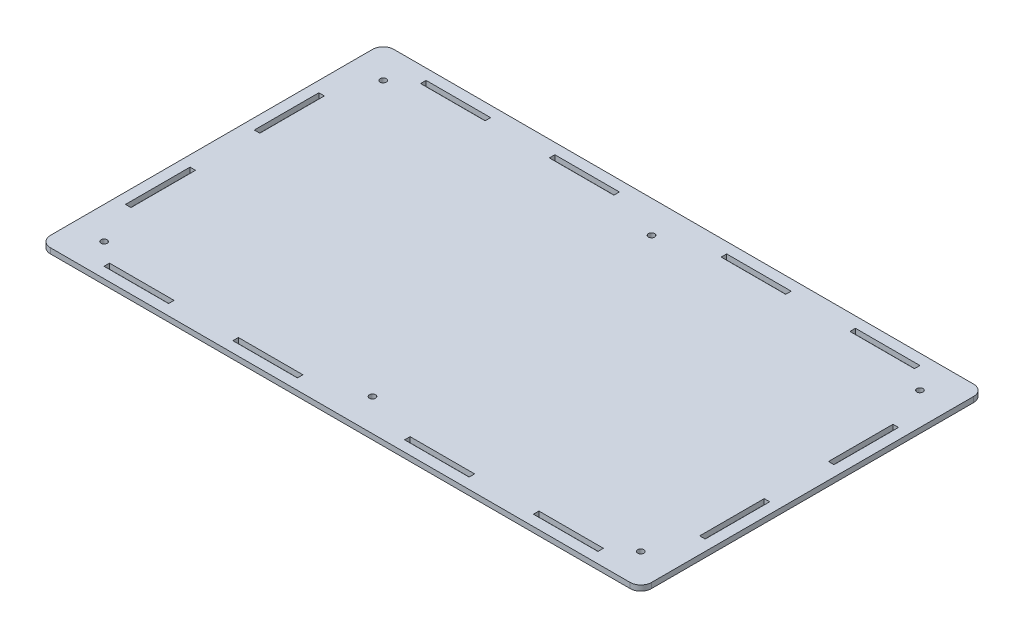
from build123d import *

# Parameters (mm, degrees)
PANEL_PROFILE_2_W       = 355.6
PANEL_PROFILE_2_H       = 203.2
PANEL_PROFILE_DEPTH     = 3.175
SKETCH8_R               = 1.8288
CUT_EXTRUDE1_DEPTH      = 10
FILLET1_R               = 6.35
SKETCH9_W               = 38.18
SKETCH9_H               = 3.25
CUT_EXTRUDE2_DEPTH      = 205.80595847
MIRROR2_COPY_1_SKETCH_W = 38.18
MIRROR2_COPY_1_SKETCH_H = 3.25
MIRROR2_COPY_1_DEPTH    = 205.80595847
SKETCH10_W              = 3.2512
SKETCH10_H              = 38.1762
CUT_EXTRUDE3_DEPTH      = 205.80595847
MIRROR4_COPY_1_SKETCH_W = 3.2512
MIRROR4_COPY_1_SKETCH_H = 38.1762
MIRROR4_COPY_1_DEPTH    = 205.80595847


with BuildPart() as part:
    # Panel Profile 2 → Panel-Profile (new body)
    with BuildSketch(Plane(origin=(0, 0, 0), x_dir=(1, 0, 0), z_dir=(0, 1, 0))):
        Rectangle(PANEL_PROFILE_2_W, PANEL_PROFILE_2_H)
    extrude(amount=-PANEL_PROFILE_DEPTH)

    # Sketch8 → Cut-Extrude1 (cut)
    with BuildSketch(Plane(origin=(0, 0, 0), x_dir=(1, 0, 0), z_dir=(0, 1, 0))):
        with Locations((-158.75, 82.55)):
            Circle(SKETCH8_R)
        with Locations((0, 82.55)):
            Circle(SKETCH8_R)
        with Locations((158.75, 82.55)):
            Circle(SKETCH8_R)
        with Locations((-158.75, -82.55)):
            Circle(SKETCH8_R)
        with Locations((0, -82.55)):
            Circle(SKETCH8_R)
        with Locations((158.75, -82.55)):
            Circle(SKETCH8_R)
    extrude(amount=-CUT_EXTRUDE1_DEPTH, mode=Mode.SUBTRACT)

    # Fillet1
    fillet1_edges = [part.edges().sort_by_distance(p)[0] for p in [
        (177.8, -1.5875, -101.6),
        (177.8, -1.5875, 101.6),
        (-177.8, -1.5875, 101.6),
        (-177.8, -1.5875, -101.6),
    ]]
    fillet(fillet1_edges, radius=FILLET1_R)

    # Sketch9 → Cut-Extrude2 (cut, symmetric)
    with BuildSketch(Plane(origin=(0, 0, 0), x_dir=(1, 0, 0), z_dir=(0, 1, 0))):
        with Locations((-127, 93.625)):
            Rectangle(SKETCH9_W, SKETCH9_H)
        with Locations((-50.8, 93.625)):
            Rectangle(SKETCH9_W, SKETCH9_H)
    cut_extrude2 = extrude(amount=CUT_EXTRUDE2_DEPTH, both=True, mode=Mode.SUBTRACT)

    # Mirror1: Cut-Extrude2 across plane
    add(cut_extrude2.mirror(Plane(origin=(0, 0, 0), x_dir=(0, 0, 1), z_dir=(1, 0, 0))), mode=Mode.SUBTRACT)

    # Mirror2: Cut-Extrude2 across plane
    add(cut_extrude2.mirror(Plane.XY), mode=Mode.SUBTRACT)

    # Mirror2 copy 1 sketch → Mirror2 copy 1 (cut, symmetric)
    with BuildSketch(Plane(origin=(0, 0, 0), x_dir=(-1, 0, 0), z_dir=(0, 1, 0))):
        with Locations((-127, 93.625)):
            Rectangle(MIRROR2_COPY_1_SKETCH_W, MIRROR2_COPY_1_SKETCH_H)
        with Locations((-50.8, 93.625)):
            Rectangle(MIRROR2_COPY_1_SKETCH_W, MIRROR2_COPY_1_SKETCH_H)
    extrude(amount=MIRROR2_COPY_1_DEPTH, both=True, mode=Mode.SUBTRACT)

    # Sketch10 → Cut-Extrude3 (cut, symmetric)
    with BuildSketch(Plane(origin=(0, 0, 0), x_dir=(1, 0, 0), z_dir=(0, 1, 0))):
        with Locations((-169.8244, 38.1)):
            Rectangle(SKETCH10_W, SKETCH10_H)
    cut_extrude3 = extrude(amount=CUT_EXTRUDE3_DEPTH, both=True, mode=Mode.SUBTRACT)

    # Mirror3: Cut-Extrude3 across plane
    add(cut_extrude3.mirror(Plane.XY), mode=Mode.SUBTRACT)

    # Mirror4: Cut-Extrude3 across plane
    add(cut_extrude3.mirror(Plane(origin=(0, 0, 0), x_dir=(0, 0, 1), z_dir=(1, 0, 0))), mode=Mode.SUBTRACT)

    # Mirror4 copy 1 sketch → Mirror4 copy 1 (cut, symmetric)
    with BuildSketch(Plane(origin=(0, 0, 0), x_dir=(-1, 0, 0), z_dir=(0, 1, 0))):
        with Locations((-169.8244, 38.1)):
            Rectangle(MIRROR4_COPY_1_SKETCH_W, MIRROR4_COPY_1_SKETCH_H)
    extrude(amount=MIRROR4_COPY_1_DEPTH, both=True, mode=Mode.SUBTRACT)


solid = part.part
